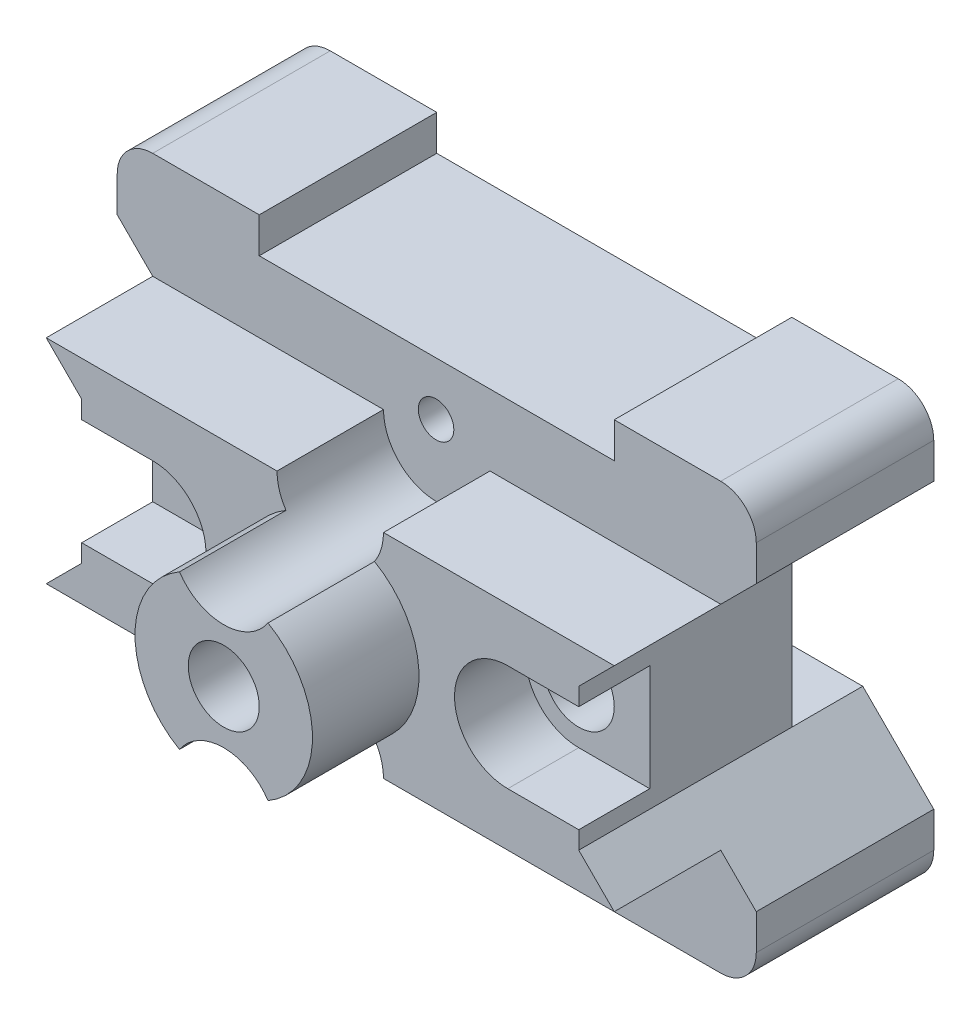
from build123d import *

# Parameters (mm, degrees)
BOSS_EXTRUDE1_DEPTH            = 60
SKETCH2_W                      = 30
SKETCH2_H                      = 10
CUT_EXTRUDE1_DEPTH             = 253
BOSS_EXTRUDE2_DEPTH            = 15
CUT_EXTRUDE5_DEPTH             = 10
SKETCH8_R                      = 5
CUT_EXTRUDE6_DEPTH             = 124
BOSS_EXTRUDE3_DEPTH            = 15
SKETCH15_W                     = 45
SKETCH15_H                     = 60
CUT_EXTRUDE8_DEPTH             = 90
BOSS_EXTRUDE4_DEPTH            = 10
F_1_2_1_2_DIAMETER_HOLE7_D     = 5
F_1_2_1_2_DIAMETER_HOLE7_DEPTH = 10
F_1_2_1_2_DIAMETER_HOLE7_TIP   = 1.357389249
F_10_0_10_DIAMETER_HOLE4_D     = 10
F_10_0_10_DIAMETER_HOLE4_DEPTH = 20
F_10_0_10_DIAMETER_HOLE4_TIP   = 2.714778498


with BuildPart() as part:
    # Sketch1 → Boss-Extrude1 (new body)
    with BuildSketch(Plane.XY):
        with BuildLine():
            Line((-90, 0), (-90, 5))
            ThreePointArc((-90, 5), (-88.535533906, 8.535533906), (-85, 10))
            Line((-85, 10), (-70, 10))
            Line((-70, 10), (-70, 5))
            Line((-70, 5), (-20, 5))
            Line((-20, 5), (-20, 10))
            Line((-20, 10), (-5, 10))
            ThreePointArc((-5, 10), (-1.464466094, 8.535533906), (0, 5))
            Line((0, 5), (0, 0))
            Line((0, 0), (-10, -10))
            Line((-10, -10), (-10, -30))
            Line((-10, -30), (0, -40))
            Line((0, -40), (0, -45))
            ThreePointArc((0, -45), (-1.464466094, -48.535533906), (-5, -50))
            Line((-5, -50), (-20, -50))
            Line((-20, -50), (-20, -45))
            Line((-20, -45), (-70, -45))
            Line((-70, -45), (-70, -50))
            Line((-70, -50), (-85, -50))
            ThreePointArc((-85, -50), (-88.535533906, -48.535533906), (-90, -45))
            Line((-90, -45), (-90, -40))
            Line((-90, -40), (-80, -30))
            Line((-80, -30), (-80, -10))
            Line((-80, -10), (-90, 0))
        make_face()
    extrude(amount=BOSS_EXTRUDE1_DEPTH)

    # Sketch2 → Cut-Extrude1 (cut)
    with BuildSketch(Plane(origin=(0, 0, 0), x_dir=(0, 0, -1), z_dir=(1, 0, 0))):
        with Locations((-30, -45)):
            Rectangle(SKETCH2_W, SKETCH2_H)
    extrude(amount=-CUT_EXTRUDE1_DEPTH, mode=Mode.SUBTRACT)

    # Sketch3 → Boss-Extrude2 (add)
    with BuildSketch(Plane.XY.offset(60)):
        with BuildLine():
            Line((-85, -5), (-80, -10))
            Line((-80, -10), (-80, -30))
            Line((-80, -30), (-85, -35))
            Line((-85, -35), (-52.5, -35))
            ThreePointArc((-52.5, -35), (-45, -27.5), (-37.5, -35))
            Line((-37.5, -35), (-5, -35))
            Line((-5, -35), (-10, -30))
            Line((-10, -30), (-10, -10))
            Line((-10, -10), (-5, -5))
            Line((-5, -5), (-37.5, -5))
            ThreePointArc((-37.5, -5), (-45, -12.5), (-52.5, -5))
            Line((-52.5, -5), (-85, -5))
        make_face()
    extrude(amount=BOSS_EXTRUDE2_DEPTH)

    # Sketch4 → Cut-Extrude5 (cut)
    with BuildSketch(Plane.XY.offset(75)):
        with BuildLine():
            Line((-80, -12.5), (-70, -12.5))
            ThreePointArc((-70, -12.5), (-62.5, -20), (-70, -27.5))
            Line((-70, -27.5), (-80, -27.5))
            Line((-80, -27.5), (-80, -12.5))
        make_face()
        with BuildLine():
            Line((-10, -12.5), (-10, -27.5))
            Line((-10, -27.5), (-20, -27.5))
            ThreePointArc((-20, -27.5), (-27.5, -20), (-20, -12.5))
            Line((-20, -12.5), (-10, -12.5))
        make_face()
    extrude(amount=-CUT_EXTRUDE5_DEPTH, mode=Mode.SUBTRACT)

    # Sketch8 → Cut-Extrude6 (cut)
    with BuildSketch(Plane.XY.offset(65)):
        with Locations((-20, -20)):
            Circle(SKETCH8_R)
        with Locations((-70, -20)):
            Circle(SKETCH8_R)
    extrude(amount=-CUT_EXTRUDE6_DEPTH, mode=Mode.SUBTRACT)

    # Sketch11 → Boss-Extrude3 (add)
    with BuildSketch(Plane.XY.offset(75)):
        with BuildLine():
            ThreePointArc((-51.236095645, -9.166666667), (-57.5, -20), (-51.236095645, -30.833333333))
            ThreePointArc((-51.236095645, -30.833333333), (-45, -27.5), (-38.763904355, -30.833333333))
            ThreePointArc((-38.763904355, -30.833333333), (-32.5, -20), (-38.763904355, -9.166666667))
            ThreePointArc((-38.763904355, -9.166666667), (-45, -12.5), (-51.236095645, -9.166666667))
        make_face()
    extrude(amount=BOSS_EXTRUDE3_DEPTH)

    # Sketch15 → Cut-Extrude8 (cut, symmetric)
    with BuildSketch(Plane.ZY.offset(80)):
        with Locations((22.5, -20)):
            Rectangle(SKETCH15_W, SKETCH15_H)
    extrude(amount=CUT_EXTRUDE8_DEPTH, both=True, mode=Mode.SUBTRACT)

    # Sketch16 → Boss-Extrude4 (add)
    with BuildSketch(Plane(origin=(0, 0, 45), x_dir=(-1, 0, 0), z_dir=(0, 0, -1))):
        with BuildLine():
            Line((10, -10), (80, -10))
            Line((80, -10), (90, 0))
            Line((90, 0), (90, 5))
            ThreePointArc((90, 5), (88.535533906, 8.535533906), (85, 10))
            Line((85, 10), (70, 10))
            Line((70, 10), (70, 5))
            Line((70, 5), (20, 5))
            Line((20, 5), (20, 10))
            Line((20, 10), (5, 10))
            ThreePointArc((5, 10), (1.464466094, 8.535533906), (0, 5))
            Line((0, 5), (0, 0))
            Line((0, 0), (10, -10))
        make_face()
        with BuildLine():
            Line((80, -30), (10, -30))
            Line((10, -30), (0, -40))
            Line((0, -40), (0, -45))
            ThreePointArc((0, -45), (1.464466094, -48.535533906), (5, -50))
            Line((5, -50), (20, -50))
            Line((20, -50), (20, -45))
            Line((20, -45), (70, -45))
            Line((70, -45), (70, -50))
            Line((70, -50), (85, -50))
            ThreePointArc((85, -50), (88.535533906, -48.535533906), (90, -45))
            Line((90, -45), (90, -40))
            Line((90, -40), (80, -30))
        make_face()
    extrude(amount=BOSS_EXTRUDE4_DEPTH)

    # Ø1.2 (1.2) Diameter Hole7
    with Locations(Plane(origin=(-45.096109005, -2.501848071, 60), x_dir=(1, 0, 0), z_dir=(0, 0, 1))):
        with Locations((0, 0), (0, -34.996303858)):
            Hole(F_1_2_1_2_DIAMETER_HOLE7_D / 2, depth=F_1_2_1_2_DIAMETER_HOLE7_DEPTH)
            with Locations((0, 0, -(F_1_2_1_2_DIAMETER_HOLE7_DEPTH + F_1_2_1_2_DIAMETER_HOLE7_TIP / 2))):  # 123° drill point
                Cone(0, F_1_2_1_2_DIAMETER_HOLE7_D / 2, F_1_2_1_2_DIAMETER_HOLE7_TIP, mode=Mode.SUBTRACT)

    # Ø10.0 (10) Diameter Hole4
    with Locations(Plane(origin=(-45, -20, 90), x_dir=(1, 0, 0), z_dir=(0, 0, 1))):
        with Locations((0, 0)):
            Hole(F_10_0_10_DIAMETER_HOLE4_D / 2, depth=F_10_0_10_DIAMETER_HOLE4_DEPTH)
            with Locations((0, 0, -(F_10_0_10_DIAMETER_HOLE4_DEPTH + F_10_0_10_DIAMETER_HOLE4_TIP / 2))):  # 123° drill point
                Cone(0, F_10_0_10_DIAMETER_HOLE4_D / 2, F_10_0_10_DIAMETER_HOLE4_TIP, mode=Mode.SUBTRACT)


solid = part.part
